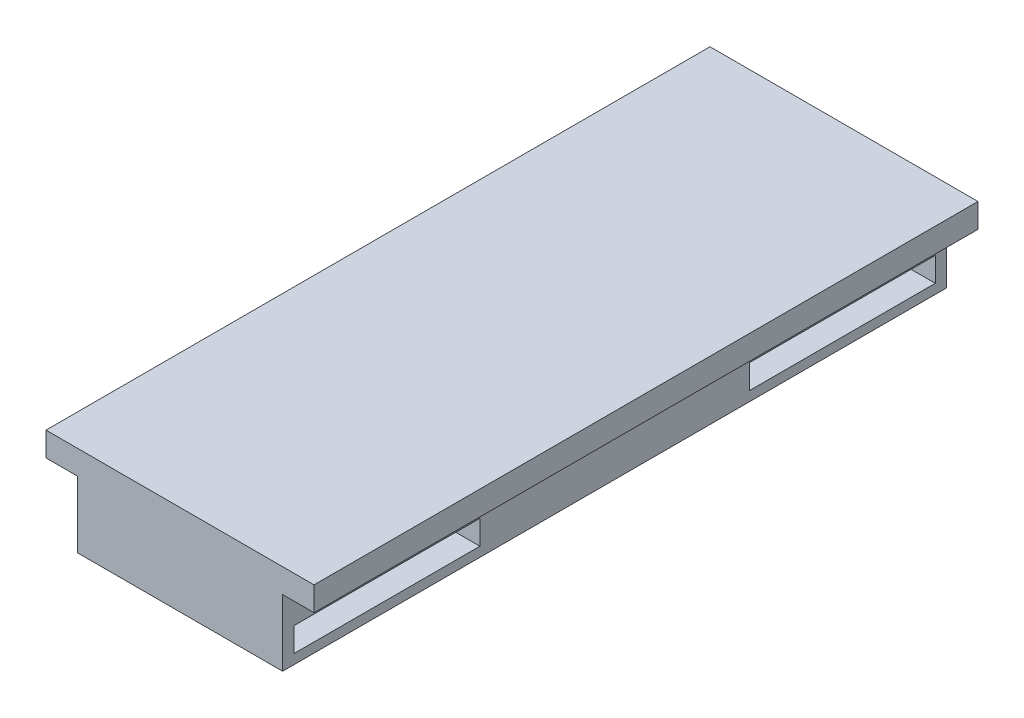
from build123d import *

# Parameters (mm, degrees)
BOSS_EXTRUDE1_DEPTH = 55
SKETCH3_R           = 7.7
CUT_EXTRUDE1_DEPTH  = 2.8
SKETCH4_R           = 7.7
SKETCH4_R_2         = 5.5
BOSS_EXTRUDE2_DEPTH = 0.8
SKETCH5_W           = 15.4
SKETCH5_H           = 2
CUT_EXTRUDE2_DEPTH  = 8.5


with BuildPart() as part:
    # Sketch2 → Boss-Extrude1 (new body)
    with BuildSketch(Plane.XY):
        Polygon((2.6, -2.280794077), (19.6, -2.280794077), (19.6, 3.219205923), (22.2, 3.219205923), (22.2, 5.219205923), (0, 5.219205923), (0, 3.219205923), (2.6, 3.219205923), align=None)
    extrude(amount=-BOSS_EXTRUDE1_DEPTH)

    # Sketch3 → Cut-Extrude1 (cut)
    with BuildSketch(Plane.XZ.offset(2.280794077)):
        with Locations((11.1, -8.64)):
            Circle(SKETCH3_R)
        with Locations((11.1, -46.36)):
            Circle(SKETCH3_R)
    extrude(amount=-CUT_EXTRUDE1_DEPTH, mode=Mode.SUBTRACT)

    # Sketch4 → Boss-Extrude2 (add)
    with BuildSketch(Plane.XZ.offset(2.280794077)):
        with Locations((11.1, -8.64)):
            Circle(SKETCH4_R)
        with Locations((11.1, -8.64)):
            Circle(SKETCH4_R_2, mode=Mode.SUBTRACT)
        with Locations((11.1, -46.36)):
            Circle(SKETCH4_R)
        with Locations((11.1, -46.36)):
            Circle(SKETCH4_R_2, mode=Mode.SUBTRACT)
    extrude(amount=-BOSS_EXTRUDE2_DEPTH)

    # Sketch5 → Cut-Extrude2 (cut)
    with BuildSketch(Plane(origin=(19.6, 0, 0), x_dir=(0, 0, -1), z_dir=(1, 0, 0))):
        with Locations((8.64, -0.480794077)):
            Rectangle(SKETCH5_W, SKETCH5_H)
        with Locations((46.36, -0.480794077)):
            Rectangle(SKETCH5_W, SKETCH5_H)
    extrude(amount=-CUT_EXTRUDE2_DEPTH, mode=Mode.SUBTRACT)


solid = part.part
